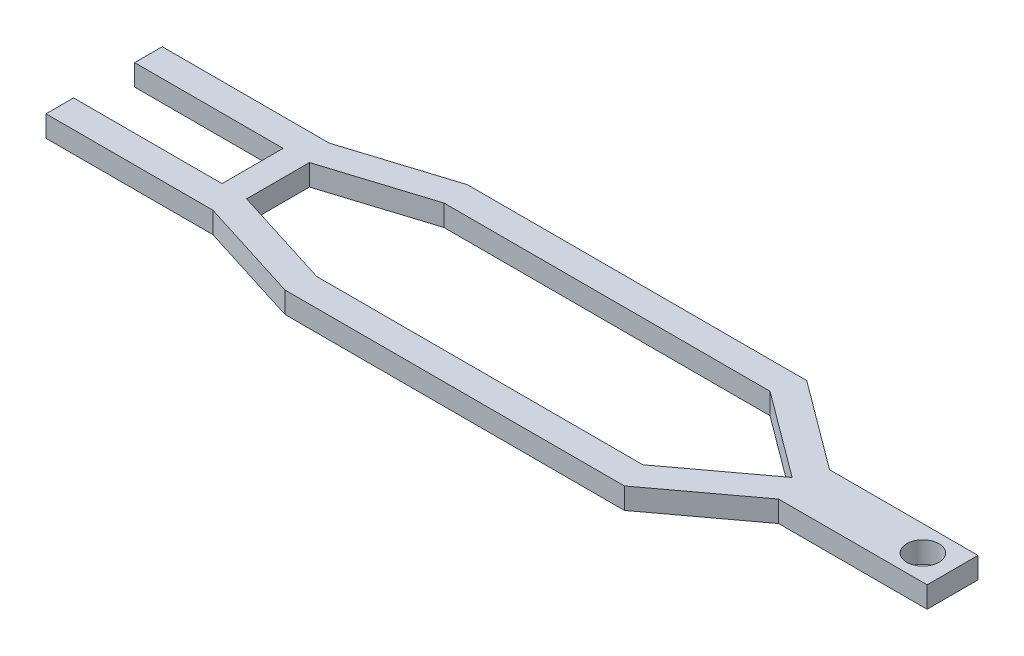
from build123d import *

# Parameters (mm, degrees)
BOSS_EXTRUDE1_DEPTH = 5
SKETCH3_R           = 3.8
CUT_EXTRUDE1_DEPTH  = 6


with BuildPart() as part:
    # Sketch2 → Boss-Extrude1 (new body)
    with BuildSketch(Plane(origin=(0, 0, 0), x_dir=(1, 0, 0), z_dir=(0, 1, 0))):
        Polygon((0, -13.7), (39.336112578, -13.7), (64.132518911, -21.5), (144.132518911, -21.5), (165, -6), (200, -6), (200, 6), (165, 6), (144.132518911, 21.5), (64.132518911, 21.5), (39.336112578, 13.7), (0, 13.7), (0, 7.2), (35, 7.2), (35, -7.2), (0, -7.2), align=None)
    extrude(amount=BOSS_EXTRUDE1_DEPTH)

    # Sketch3 → Cut-Extrude1 (cut, through all)
    with BuildSketch(Plane(origin=(0, 5, 0), x_dir=(1, 0, 0), z_dir=(0, 1, 0))):
        with Locations((193, 0)):
            Circle(SKETCH3_R)
        Polygon((41, 7.409395112), (41, -7.409395112), (65.130733731, -15), (141.982577641, -15), (162.176914179, 0), (141.982577641, 15), (65.130733731, 15), align=None)
    extrude(amount=-CUT_EXTRUDE1_DEPTH, mode=Mode.SUBTRACT)


solid = part.part
